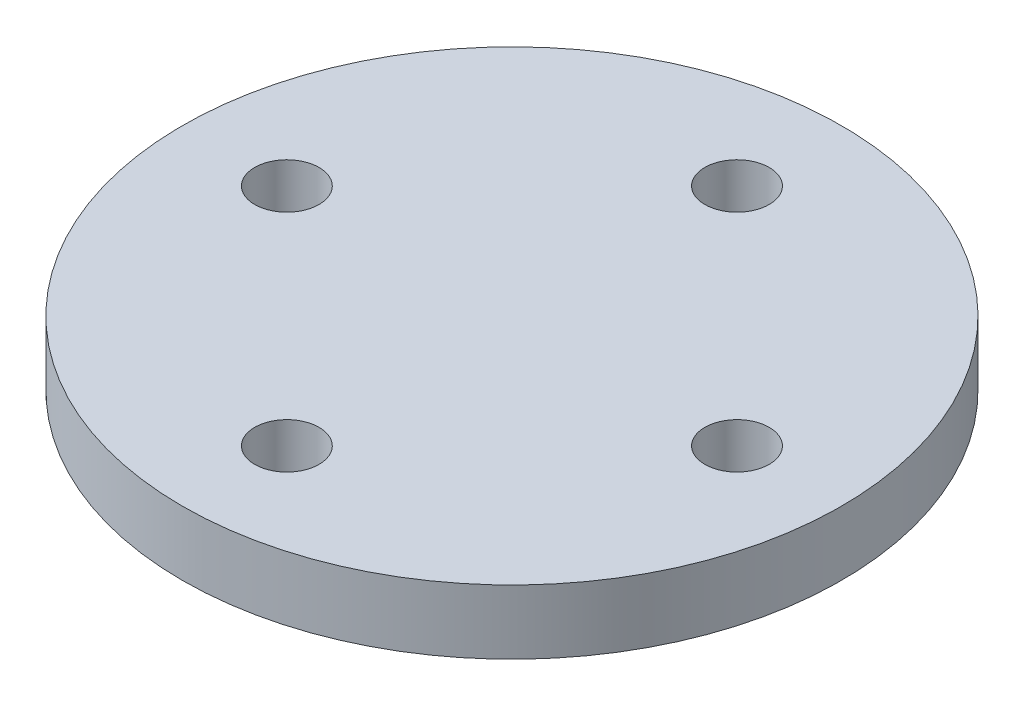
from build123d import *

# Parameters (mm, degrees)
SKETCH_1_R          = 10.25
EXTRUDE_1_DEPTH     = 2
SKETCH_2_R          = 4
SKETCH_2_R_2        = 3
EXTRUDE_2_DEPTH     = 3
SKETCH_4_R          = 1
CUT_EXTRUDE_1_DEPTH = 3


with BuildPart() as part:
    # 草图1 → 凸台-拉伸1 (new body)
    with BuildSketch(Plane(origin=(0, 0, 0), x_dir=(1, 0, 0), z_dir=(0, 1, 0))):
        Circle(SKETCH_1_R)
    extrude(amount=EXTRUDE_1_DEPTH)

    # 草图2 → 凸台-拉伸2 (add)
    with BuildSketch(Plane.XZ):
        Circle(SKETCH_2_R)
        Circle(SKETCH_2_R_2, mode=Mode.SUBTRACT)
    extrude(amount=EXTRUDE_2_DEPTH)

    # 草图4 → 切除-拉伸1 (cut)
    with BuildSketch(Plane(origin=(0, 2, 0), x_dir=(1, 0, 0), z_dir=(0, 1, 0))):
        with Locations((-7, 0)):
            Circle(SKETCH_4_R)
        with Locations((0, 7)):
            Circle(SKETCH_4_R)
        with Locations((7, 0)):
            Circle(SKETCH_4_R)
        with Locations((0, -7)):
            Circle(SKETCH_4_R)
    extrude(amount=-CUT_EXTRUDE_1_DEPTH, mode=Mode.SUBTRACT)


solid = part.part
